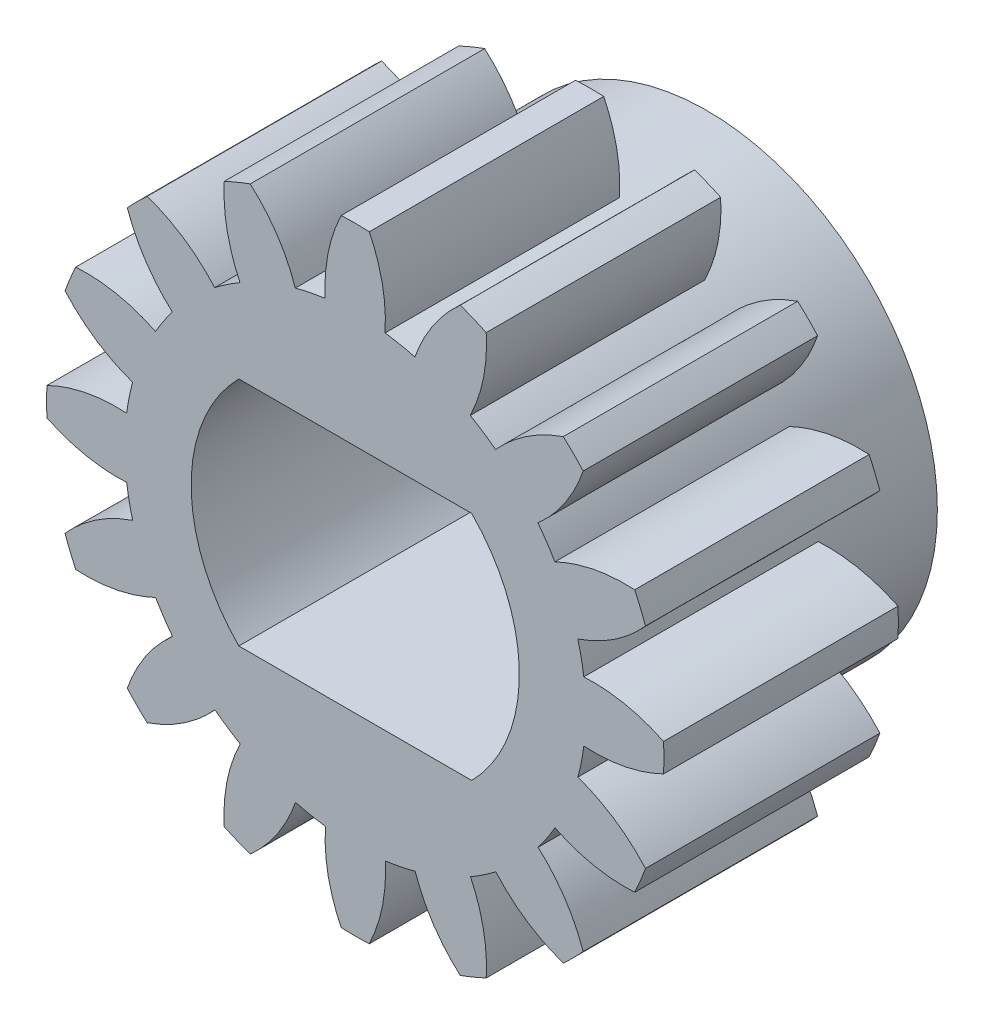
from build123d import *

# Parameters (mm, degrees)
EXTRUDE_1_DEPTH     = 4.5
SKETCH_2_R          = 4.629612549
SKETCH_2_R_2        = 2.95
CUT_EXTRUDE_1_DEPTH = 1.5
CUT_EXTRUDE_2_DEPTH = 5.5


with BuildPart() as part:
    # 草图1 → 凸台-拉伸1 (new body)
    with BuildSketch(Plane.XY):
        with BuildLine():
            ThreePointArc((-0.384889205, 2.924783804), (-0.577129312, 2.892995292), (-0.766851553, 2.848585385))
            add(Edge.make_bspline(
                [(-1.343774928, 3.714400213), (-0.94147634, 3.356869473), (-0.766851553, 2.848585385)],
                knots=[0, 0, 0, 1, 1, 1], degree=2))
            ThreePointArc((-1.343774928, 3.714400213), (-1.511621166, 3.649315203), (-1.676327572, 3.576650091))
            add(Edge.make_bspline(
                [(-1.676327572, 3.576650091), (-1.705452706, 3.039783662), (-1.474857564, 2.554857171)],
                knots=[0, 0, 0, 1, 1, 1], degree=2))
            ThreePointArc((-1.474857564, 2.554857171), (-1.640299327, 2.451921311), (-1.798584887, 2.338288349))
            add(Edge.make_bspline(
                [(-2.662925575, 2.917417931), (-2.154429053, 2.741055602), (-1.798584887, 2.338288349)],
                knots=[0, 0, 0, 1, 1, 1], degree=2))
            ThreePointArc((-2.662925575, 2.917417931), (-2.793088324, 2.793055247), (-2.917449466, 2.662891025))
            add(Edge.make_bspline(
                [(-2.917449466, 2.662891025), (-2.738907694, 2.155745413), (-2.340292228, 1.795976694)],
                knots=[0, 0, 0, 1, 1, 1], degree=2))
            ThreePointArc((-2.340292228, 1.795976694), (-2.453748639, 1.637564538), (-2.556499976, 1.472008109))
            add(Edge.make_bspline(
                [(-3.576669943, 1.676285215), (-3.039389472, 1.707940863), (-2.556499976, 1.472008109)],
                knots=[0, 0, 0, 1, 1, 1], degree=2))
            ThreePointArc((-3.576669943, 1.676285215), (-3.649333104, 1.511577949), (-3.714416127, 1.34373094))
            add(Edge.make_bspline(
                [(-3.714416127, 1.34373094), (-3.355388814, 0.943514467), (-2.849438616, 0.763675046)],
                knots=[0, 0, 0, 1, 1, 1], degree=2))
            ThreePointArc((-2.849438616, 0.763675046), (-2.893636964, 0.573903409), (-2.925211118, 0.381627978))
            add(Edge.make_bspline(
                [(-3.945898734, 0.179953271), (-3.461630396, 0.41480761), (-2.925211118, 0.381627978)],
                knots=[0, 0, 0, 1, 1, 1], degree=2))
            ThreePointArc((-3.945898734, 0.179953271), (-3.95, -2.3389e-05), (-3.945896603, -0.18))
            add(Edge.make_bspline(
                [(-3.945896603, -0.18), (-3.461042404, -0.412358003), (-2.924783804, -0.384889205)],
                knots=[0, 0, 0, 1, 1, 1], degree=2))
            ThreePointArc((-2.924783804, -0.384889205), (-2.892995292, -0.577129312), (-2.848585385, -0.766851553))
            add(Edge.make_bspline(
                [(-3.714400213, -1.343774928), (-3.356869473, -0.94147634), (-2.848585385, -0.766851553)],
                knots=[0, 0, 0, 1, 1, 1], degree=2))
            ThreePointArc((-3.714400213, -1.343774928), (-3.649315203, -1.511621166), (-3.576650091, -1.676327572))
            add(Edge.make_bspline(
                [(-3.576650091, -1.676327572), (-3.039783662, -1.705452706), (-2.554857171, -1.474857564)],
                knots=[0, 0, 0, 1, 1, 1], degree=2))
            ThreePointArc((-2.554857171, -1.474857564), (-2.451921311, -1.640299327), (-2.338288349, -1.798584887))
            add(Edge.make_bspline(
                [(-2.917417931, -2.662925575), (-2.741055602, -2.154429053), (-2.338288349, -1.798584887)],
                knots=[0, 0, 0, 1, 1, 1], degree=2))
            ThreePointArc((-2.917417931, -2.662925575), (-2.793055247, -2.793088324), (-2.662891025, -2.917449466))
            add(Edge.make_bspline(
                [(-2.662891025, -2.917449466), (-2.155745413, -2.738907694), (-1.795976694, -2.340292228)],
                knots=[0, 0, 0, 1, 1, 1], degree=2))
            ThreePointArc((-1.795976694, -2.340292228), (-1.637564538, -2.453748639), (-1.472008109, -2.556499976))
            add(Edge.make_bspline(
                [(-1.676285215, -3.576669943), (-1.707940863, -3.039389472), (-1.472008109, -2.556499976)],
                knots=[0, 0, 0, 1, 1, 1], degree=2))
            ThreePointArc((-1.676285215, -3.576669943), (-1.511577949, -3.649333104), (-1.34373094, -3.714416127))
            add(Edge.make_bspline(
                [(-1.34373094, -3.714416127), (-0.943514467, -3.355388814), (-0.763675046, -2.849438616)],
                knots=[0, 0, 0, 1, 1, 1], degree=2))
            ThreePointArc((-0.763675046, -2.849438616), (-0.573903409, -2.893636964), (-0.381627978, -2.925211118))
            add(Edge.make_bspline(
                [(-0.179953271, -3.945898734), (-0.41480761, -3.461630396), (-0.381627978, -2.925211118)],
                knots=[0, 0, 0, 1, 1, 1], degree=2))
            ThreePointArc((-0.179953271, -3.945898734), (2.3389e-05, -3.95), (0.18, -3.945896603))
            add(Edge.make_bspline(
                [(0.18, -3.945896603), (0.412358003, -3.461042404), (0.384889205, -2.924783804)],
                knots=[0, 0, 0, 1, 1, 1], degree=2))
            ThreePointArc((0.384889205, -2.924783804), (0.577129312, -2.892995292), (0.766851553, -2.848585385))
            add(Edge.make_bspline(
                [(1.343774928, -3.714400213), (0.94147634, -3.356869473), (0.766851553, -2.848585385)],
                knots=[0, 0, 0, 1, 1, 1], degree=2))
            ThreePointArc((1.343774928, -3.714400213), (1.511621166, -3.649315203), (1.676327572, -3.576650091))
            add(Edge.make_bspline(
                [(1.676327572, -3.576650091), (1.705452706, -3.039783662), (1.474857564, -2.554857171)],
                knots=[0, 0, 0, 1, 1, 1], degree=2))
            ThreePointArc((1.474857564, -2.554857171), (1.640299327, -2.451921311), (1.798584887, -2.338288349))
            add(Edge.make_bspline(
                [(2.662925575, -2.917417931), (2.154429053, -2.741055602), (1.798584887, -2.338288349)],
                knots=[0, 0, 0, 1, 1, 1], degree=2))
            ThreePointArc((2.662925575, -2.917417931), (2.793088324, -2.793055247), (2.917449466, -2.662891025))
            add(Edge.make_bspline(
                [(2.917449466, -2.662891025), (2.738907694, -2.155745413), (2.340292228, -1.795976694)],
                knots=[0, 0, 0, 1, 1, 1], degree=2))
            ThreePointArc((2.340292228, -1.795976694), (2.453748639, -1.637564538), (2.556499976, -1.472008109))
            add(Edge.make_bspline(
                [(3.576669943, -1.676285215), (3.039389472, -1.707940863), (2.556499976, -1.472008109)],
                knots=[0, 0, 0, 1, 1, 1], degree=2))
            ThreePointArc((3.576669943, -1.676285215), (3.649333104, -1.511577949), (3.714416127, -1.34373094))
            add(Edge.make_bspline(
                [(3.714416127, -1.34373094), (3.355388814, -0.943514467), (2.849438616, -0.763675046)],
                knots=[0, 0, 0, 1, 1, 1], degree=2))
            ThreePointArc((2.849438616, -0.763675046), (2.893636964, -0.573903409), (2.925211118, -0.381627978))
            add(Edge.make_bspline(
                [(3.945898734, -0.179953271), (3.461630396, -0.41480761), (2.925211118, -0.381627978)],
                knots=[0, 0, 0, 1, 1, 1], degree=2))
            ThreePointArc((3.945898734, -0.179953271), (3.95, 2.3389e-05), (3.945896603, 0.18))
            add(Edge.make_bspline(
                [(3.945896603, 0.18), (3.461042404, 0.412358003), (2.924783804, 0.384889205)],
                knots=[0, 0, 0, 1, 1, 1], degree=2))
            ThreePointArc((2.924783804, 0.384889205), (2.892995292, 0.577129312), (2.848585385, 0.766851553))
            add(Edge.make_bspline(
                [(3.714400213, 1.343774928), (3.356869473, 0.94147634), (2.848585385, 0.766851553)],
                knots=[0, 0, 0, 1, 1, 1], degree=2))
            ThreePointArc((3.714400213, 1.343774928), (3.649315203, 1.511621166), (3.576650091, 1.676327572))
            add(Edge.make_bspline(
                [(3.576650091, 1.676327572), (3.039783662, 1.705452706), (2.554857171, 1.474857564)],
                knots=[0, 0, 0, 1, 1, 1], degree=2))
            ThreePointArc((2.554857171, 1.474857564), (2.451921311, 1.640299327), (2.338288349, 1.798584887))
            add(Edge.make_bspline(
                [(2.917417931, 2.662925575), (2.741055602, 2.154429053), (2.338288349, 1.798584887)],
                knots=[0, 0, 0, 1, 1, 1], degree=2))
            ThreePointArc((2.917417931, 2.662925575), (2.793055247, 2.793088324), (2.662891025, 2.917449466))
            add(Edge.make_bspline(
                [(2.662891025, 2.917449466), (2.155745413, 2.738907694), (1.795976694, 2.340292228)],
                knots=[0, 0, 0, 1, 1, 1], degree=2))
            ThreePointArc((1.795976694, 2.340292228), (1.637564538, 2.453748639), (1.472008109, 2.556499976))
            add(Edge.make_bspline(
                [(1.676285215, 3.576669943), (1.707940863, 3.039389472), (1.472008109, 2.556499976)],
                knots=[0, 0, 0, 1, 1, 1], degree=2))
            ThreePointArc((1.676285215, 3.576669943), (1.511577949, 3.649333104), (1.34373094, 3.714416127))
            add(Edge.make_bspline(
                [(1.34373094, 3.714416127), (0.943514467, 3.355388814), (0.763675046, 2.849438616)],
                knots=[0, 0, 0, 1, 1, 1], degree=2))
            ThreePointArc((0.763675046, 2.849438616), (0.573903409, 2.893636964), (0.381627978, 2.925211118))
            add(Edge.make_bspline(
                [(0.179953271, 3.945898734), (0.41480761, 3.461630396), (0.381627978, 2.925211118)],
                knots=[0, 0, 0, 1, 1, 1], degree=2))
            ThreePointArc((0.179953271, 3.945898734), (-2.3389e-05, 3.95), (-0.18, 3.945896603))
            add(Edge.make_bspline(
                [(-0.18, 3.945896603), (-0.412358003, 3.461042404), (-0.384889205, 2.924783804)],
                knots=[0, 0, 0, 1, 1, 1], degree=2))
        make_face()
    extrude(amount=EXTRUDE_1_DEPTH)

    # 草图2 → 切除-拉伸1 (cut)
    with BuildSketch(Plane(origin=(0, 0, 0), x_dir=(-1, 0, 0), z_dir=(0, 0, -1))):
        Circle(SKETCH_2_R)
        Circle(SKETCH_2_R_2, mode=Mode.SUBTRACT)
    extrude(amount=-CUT_EXTRUDE_1_DEPTH, mode=Mode.SUBTRACT)

    # 草图3 → 切除-拉伸2 (cut, through all)
    with BuildSketch(Plane.XY.offset(4.5)):
        with BuildLine():
            Line((-1.489832205, 1.48), (1.489832205, 1.48))
            ThreePointArc((1.489832205, 1.48), (2.1, 0), (1.489832205, -1.48))
            Line((1.489832205, -1.48), (-1.489832205, -1.48))
            ThreePointArc((-1.489832205, -1.48), (-2.1, 0), (-1.489832205, 1.48))
        make_face()
    extrude(amount=-CUT_EXTRUDE_2_DEPTH, mode=Mode.SUBTRACT)


solid = part.part
